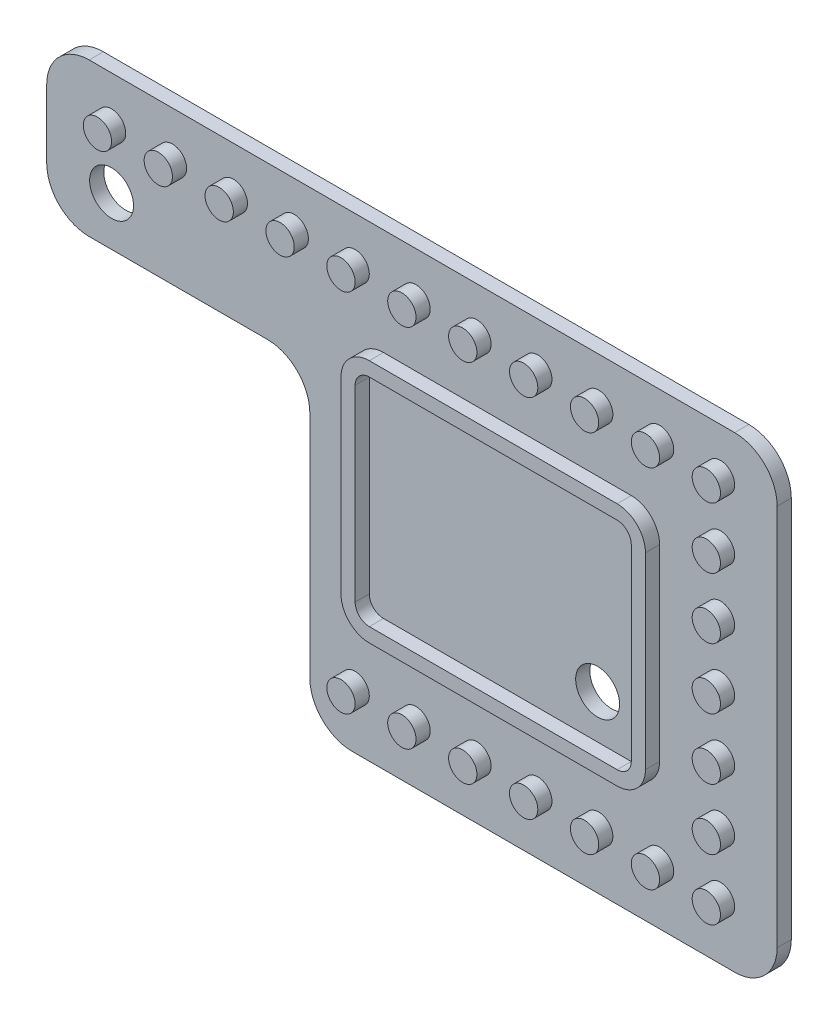
from build123d import *

# Parameters (mm, degrees)
BOSS_EXTRUDE1_DEPTH = 1
SKETCH2_R           = 1
BOSS_EXTRUDE2_DEPTH = 1
FILLET1_R           = 3
CUT_EXTRUDE1_REACH  = 3
SKETCH3_R           = 1.55


with BuildPart() as part:
    # Sketch1 → Boss-Extrude1 (new body)
    with BuildSketch(Plane.XY):
        Polygon((-8, 5), (-8, 38), (-59.580513121, 38), (-59.580513121, 27.2), (-41, 27.2), (-41, 5), align=None)
    extrude(amount=BOSS_EXTRUDE1_DEPTH)

    # Sketch2 → Boss-Extrude2 (add)
    with BuildSketch(Plane.XY.offset(1)):
        with Locations((-12, 9)):
            Circle(SKETCH2_R)
        with Locations((-12, 13.3)):
            Circle(SKETCH2_R)
        with Locations((-12, 17.6)):
            Circle(SKETCH2_R)
        with Locations((-12, 21.9)):
            Circle(SKETCH2_R)
        with Locations((-12, 26.2)):
            Circle(SKETCH2_R)
        with Locations((-12, 30.5)):
            Circle(SKETCH2_R)
        with Locations((-12, 34.8)):
            Circle(SKETCH2_R)
        with Locations((-16.3, 9)):
            Circle(SKETCH2_R)
        with Locations((-20.6, 9)):
            Circle(SKETCH2_R)
        with Locations((-24.9, 9)):
            Circle(SKETCH2_R)
        with Locations((-29.2, 9)):
            Circle(SKETCH2_R)
        with Locations((-33.5, 9)):
            Circle(SKETCH2_R)
        with Locations((-37.8, 9)):
            Circle(SKETCH2_R)
        with Locations((-16.3, 34.8)):
            Circle(SKETCH2_R)
        with Locations((-20.6, 34.8)):
            Circle(SKETCH2_R)
        with Locations((-24.9, 34.8)):
            Circle(SKETCH2_R)
        with Locations((-29.2, 34.8)):
            Circle(SKETCH2_R)
        with Locations((-33.5, 34.8)):
            Circle(SKETCH2_R)
        with Locations((-37.8, 34.8)):
            Circle(SKETCH2_R)
        with Locations((-42.1, 34.8)):
            Circle(SKETCH2_R)
        with Locations((-46.4, 34.8)):
            Circle(SKETCH2_R)
        with Locations((-50.7, 34.8)):
            Circle(SKETCH2_R)
        with Locations((-55, 34.8)):
            Circle(SKETCH2_R)
        with BuildLine():
            Line((-35.8, 30.5), (-18.3, 30.5))
            ThreePointArc((-18.3, 30.5), (-16.885786438, 29.914213562), (-16.3, 28.5))
            Line((-16.3, 28.5), (-16.3, 15.236025644))
            ThreePointArc((-16.3, 15.236025644), (-16.885786438, 13.821812082), (-18.3, 13.236025644))
            Line((-18.3, 13.236025644), (-35.8, 13.236025644))
            ThreePointArc((-35.8, 13.236025644), (-37.214213562, 13.821812082), (-37.8, 15.236025644))
            Line((-37.8, 15.236025644), (-37.8, 28.5))
            ThreePointArc((-37.8, 28.5), (-37.214213562, 29.914213562), (-35.8, 30.5))
        make_face()
        with BuildLine():
            Line((-35.8, 29.5), (-18.3, 29.5))
            ThreePointArc((-18.3, 29.5), (-17.592893219, 29.207106781), (-17.3, 28.5))
            Line((-17.3, 28.5), (-17.3, 15.236025644))
            ThreePointArc((-17.3, 15.236025644), (-17.592893219, 14.528918863), (-18.3, 14.236025644))
            Line((-18.3, 14.236025644), (-35.8, 14.236025644))
            ThreePointArc((-35.8, 14.236025644), (-36.507106781, 14.528918863), (-36.8, 15.236025644))
            Line((-36.8, 15.236025644), (-36.8, 28.5))
            ThreePointArc((-36.8, 28.5), (-36.507106781, 29.207106781), (-35.8, 29.5))
        make_face(mode=Mode.SUBTRACT)
    extrude(amount=BOSS_EXTRUDE2_DEPTH)

    # Fillet1
    fillet1_edges = [part.edges().sort_by_distance(p)[0] for p in [
        (-41, 5, 0.5),
        (-41, 27.2, 0.5),
        (-59.580513121, 27.2, 0.5),
        (-59.580513121, 38, 0.5),
        (-8, 38, 0.5),
        (-8, 5, 0.5),
    ]]
    fillet(fillet1_edges, radius=FILLET1_R)

    # Sketch3 → Cut-Extrude1 (cut, up to next)
    with BuildSketch(Plane.XY.offset(1), mode=Mode.PRIVATE) as cut_extrude1_sk1:
        with Locations((-20.677552724, 17.314204089)):
            Circle(SKETCH3_R)
    cut_extrude1_tool1 = extrude(cut_extrude1_sk1.sketch, amount=-CUT_EXTRUDE1_REACH, mode=Mode.PRIVATE) & part.part
    add(cut_extrude1_tool1.solids().sort_by_distance((-20.677553, 17.314204, 1))[0], mode=Mode.SUBTRACT)
    # Sketch3 → Cut-Extrude1 (cut, up to next)
    with BuildSketch(Plane.XY.offset(1), mode=Mode.PRIVATE) as cut_extrude1_sk2:
        with Locations((-55, 30.651276125)):
            Circle(SKETCH3_R)
    cut_extrude1_tool2 = extrude(cut_extrude1_sk2.sketch, amount=-CUT_EXTRUDE1_REACH, mode=Mode.PRIVATE) & part.part
    add(cut_extrude1_tool2.solids().sort_by_distance((-55, 30.651276, 1))[0], mode=Mode.SUBTRACT)


solid = part.part
